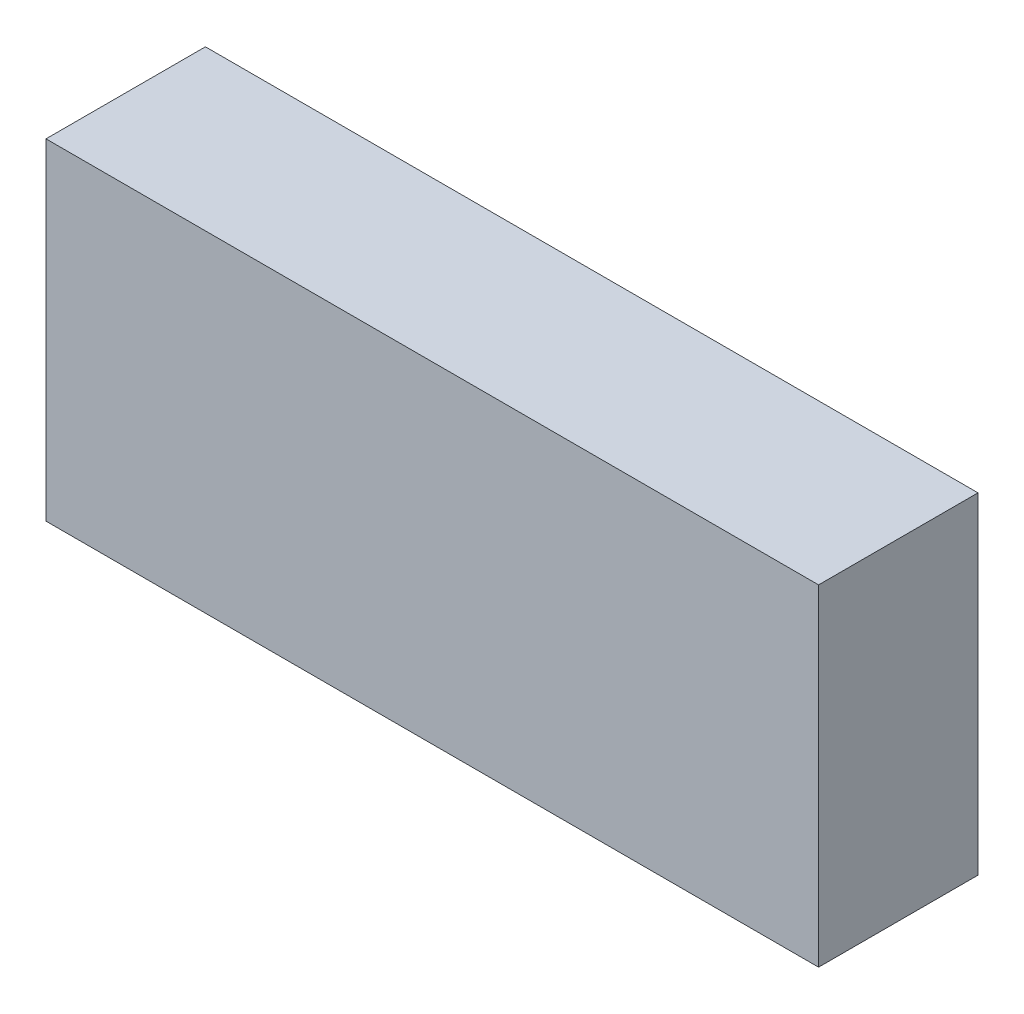
from build123d import *

# Parameters (mm, degrees)
SKETCH_1_W      = 63
SKETCH_1_H      = 27
EXTRUDE_1_DEPTH = 13


with BuildPart() as part:
    # 草图1 → 凸台-拉伸1 (new body)
    with BuildSketch(Plane.XY):
        Rectangle(SKETCH_1_W, SKETCH_1_H)
    extrude(amount=EXTRUDE_1_DEPTH)


solid = part.part
